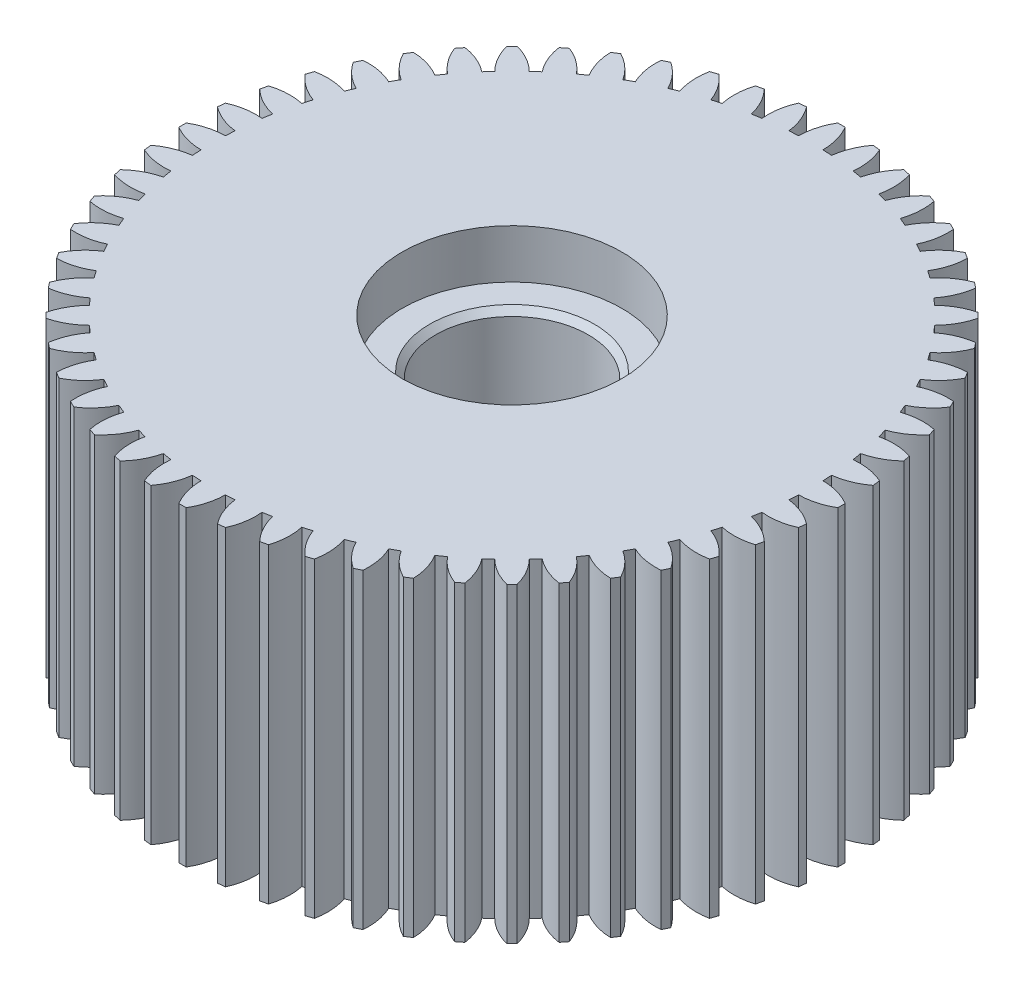
from build123d import *

# Parameters (mm, degrees)
SKETCH2_R           = 24.5
BOSS_EXTRUDE1_DEPTH = 25.5
BOSS_EXTRUDE2_DEPTH = 25.5
SKETCH4_R           = 9
CUT_EXTRUDE1_DEPTH  = 4
SKETCH5_R           = 6.25
CUT_EXTRUDE3_DEPTH  = 30
CHAMFER1_SIZE       = 0.5


with BuildPart() as part:
    # Sketch2 → Boss-Extrude1 (new body)
    with BuildSketch(Plane(origin=(0, 0, 0), x_dir=(1, 0, 0), z_dir=(0, 1, 0))):
        Circle(SKETCH2_R)
    extrude(amount=BOSS_EXTRUDE1_DEPTH)

    # Sketch3 → Boss-Extrude2 (add)
    with BuildSketch(Plane(origin=(0, 25.5, 0), x_dir=(1, 0, 0), z_dir=(0, 1, 0))):
        with BuildLine():
            Line((0.3, 26.998333282), (-0.3, 26.998333282))
            ThreePointArc((-0.3, 26.998333282), (-0.817526503, 25.785516541), (-1, 24.47958333))
            ThreePointArc((-1, 24.47958333), (0, 24.5), (1, 24.47958333))
            ThreePointArc((1, 24.47958333), (0.817526503, 25.785516541), (0.3, 26.998333282))
        make_face()
        with BuildLine():
            ThreePointArc((-1.747131513, 24.437625324), (-2.074675783, 25.714916551), (-2.724740579, 26.862162772))
            Line((-2.724740579, 26.862162772), (-3.320967905, 26.794984086))
            ThreePointArc((-3.320967905, 26.794984086), (-3.699447918, 25.531848698), (-3.734555933, 24.213696372))
            ThreePointArc((-3.734555933, 24.213696372), (-2.743129665, 24.345949142), (-1.747131513, 24.437625324))
        make_face()
        with BuildLine():
            Line((3.320967905, 26.794984086), (2.724740579, 26.862162772))
            ThreePointArc((2.724740579, 26.862162772), (2.074675783, 25.714916551), (1.747131513, 24.437625324))
            ThreePointArc((1.747131513, 24.437625324), (2.743129665, 24.345949142), (3.734555933, 24.213696372))
            ThreePointArc((3.734555933, 24.213696372), (3.699447918, 25.531848698), (3.320967905, 26.794984086))
        make_face()
        with BuildLine():
            ThreePointArc((-4.472291833, 24.088350001), (-4.940787817, 25.320936566), (-5.715215963, 26.388184979))
            Line((-5.715215963, 26.388184979), (-6.300172711, 26.254672419))
            ThreePointArc((-6.300172711, 26.254672419), (-6.534846629, 24.957103045), (-6.422147658, 23.643308133))
            ThreePointArc((-6.422147658, 23.643308133), (-5.451762882, 23.885733848), (-4.472291833, 24.088350001))
        make_face()
        with BuildLine():
            Line((6.300172711, 26.254672419), (5.715215963, 26.388184979))
            ThreePointArc((5.715215963, 26.388184979), (4.940787817, 25.320936566), (4.472291833, 24.088350001))
            ThreePointArc((4.472291833, 24.088350001), (5.451762882, 23.885733848), (6.422147658, 23.643308133))
            ThreePointArc((6.422147658, 23.643308133), (6.534846629, 24.957103045), (6.300172711, 26.254672419))
        make_face()
        with BuildLine():
            ThreePointArc((-7.141210489, 23.4361497), (-7.744766577, 24.608531113), (-8.633819192, 25.582360449))
            Line((-8.633819192, 25.582360449), (-9.20014919, 25.384193012))
            ThreePointArc((-9.20014919, 25.384193012), (-9.288065853, 24.06850734), (-9.02897715, 22.775591576))
            ThreePointArc((-9.02897715, 22.775591576), (-8.091837018, 23.125141593), (-7.141210489, 23.4361497))
        make_face()
        with BuildLine():
            Line((9.20014919, 25.384193012), (8.633819192, 25.582360449))
            ThreePointArc((8.633819192, 25.582360449), (7.744766577, 24.608531113), (7.141210489, 23.4361497))
            ThreePointArc((7.141210489, 23.4361497), (8.091837018, 23.125141593), (9.02897715, 22.775591576))
            ThreePointArc((9.02897715, 22.775591576), (9.288065853, 24.06850734), (9.20014919, 25.384193012))
        make_face()
        with BuildLine():
            ThreePointArc((-9.720324279, 22.489226218), (-10.451350404, 23.586659102), (-11.443847134, 24.454822894))
            Line((-11.443847134, 24.454822894), (-11.984428455, 24.194492651))
            ThreePointArc((-11.984428455, 24.194492651), (-11.924482259, 22.87723619), (-11.522262015, 21.62145874))
            ThreePointArc((-11.522262015, 21.62145874), (-10.630151608, 22.073737264), (-9.720324279, 22.489226218))
        make_face()
        with BuildLine():
            Line((11.984428455, 24.194492651), (11.443847134, 24.454822894))
            ThreePointArc((11.443847134, 24.454822894), (10.451350404, 23.586659102), (9.720324279, 22.489226218))
            ThreePointArc((9.720324279, 22.489226218), (10.630151608, 22.073737264), (11.522262015, 21.62145874))
            ThreePointArc((11.522262015, 21.62145874), (11.924482259, 22.87723619), (11.984428455, 24.194492651))
        make_face()
        with BuildLine():
            ThreePointArc((-12.177199352, 21.259487669), (-13.026502436, 22.268171167), (-14.109962059, 23.019751752))
            Line((-14.109962059, 23.019751752), (-14.617996578, 22.700532506))
            ThreePointArc((-14.617996578, 22.700532506), (-14.410941382, 21.398270522), (-13.87064775, 20.195423516))
            ThreePointArc((-13.87064775, 20.195423516), (-13.034785875, 20.744742881), (-12.177199352, 21.259487669))
        make_face()
        with BuildLine():
            Line((14.617996578, 22.700532506), (14.109962059, 23.019751752))
            ThreePointArc((14.109962059, 23.019751752), (13.026502436, 22.268171167), (12.177199352, 21.259487669))
            ThreePointArc((12.177199352, 21.259487669), (13.034785875, 20.744742881), (13.87064775, 20.195423516))
            ThreePointArc((13.87064775, 20.195423516), (14.410941382, 21.398270522), (14.617996578, 22.700532506))
        make_face()
        with BuildLine():
            ThreePointArc((-14.480939077, 19.762398727), (-15.437838641, 20.66964806), (-16.598636024, 21.295193875))
            Line((-16.598636024, 21.295193875), (-17.067734913, 20.921099993))
            ThreePointArc((-17.067734913, 20.921099993), (-16.716174556, 19.650209186), (-16.044602042, 18.515419123))
            ThreePointArc((-16.044602042, 18.515419123), (-15.275500146, 19.15487132), (-14.480939077, 19.762398727))
        make_face()
        with BuildLine():
            Line((17.067734913, 20.921099993), (16.598636024, 21.295193875))
            ThreePointArc((16.598636024, 21.295193875), (15.437838641, 20.66964806), (14.480939077, 19.762398727))
            ThreePointArc((14.480939077, 19.762398727), (15.275500146, 19.15487132), (16.044602042, 18.515419123))
            ThreePointArc((16.044602042, 18.515419123), (16.716174556, 19.650209186), (17.067734913, 20.921099993))
        make_face()
        with BuildLine():
            ThreePointArc((-16.602572592, 18.016786154), (-17.655035069, 18.811192136), (-18.87857251, 19.302836579))
            Line((-18.87857251, 19.302836579), (-19.302836579, 18.87857251))
            ThreePointArc((-19.302836579, 18.87857251), (-18.811192136, 17.655035069), (-18.016786154, 16.602572592))
            ThreePointArc((-18.016786154, 16.602572592), (-17.324116139, 17.324116139), (-16.602572592, 18.016786154))
        make_face()
        with BuildLine():
            Line((19.302836579, 18.87857251), (18.87857251, 19.302836579))
            ThreePointArc((18.87857251, 19.302836579), (17.655035069, 18.811192136), (16.602572592, 18.016786154))
            ThreePointArc((16.602572592, 18.016786154), (17.324116139, 17.324116139), (18.016786154, 16.602572592))
            ThreePointArc((18.016786154, 16.602572592), (18.811192136, 17.655035069), (19.302836579, 18.87857251))
        make_face()
        with BuildLine():
            ThreePointArc((-18.515419123, 16.044602042), (-19.650209186, 16.716174556), (-20.921099993, 17.067734913))
            Line((-20.921099993, 17.067734913), (-21.295193875, 16.598636024))
            ThreePointArc((-21.295193875, 16.598636024), (-20.66964806, 15.437838641), (-19.762398727, 14.480939077))
            ThreePointArc((-19.762398727, 14.480939077), (-19.15487132, 15.275500146), (-18.515419123, 16.044602042))
        make_face()
        with BuildLine():
            Line((21.295193875, 16.598636024), (20.921099993, 17.067734913))
            ThreePointArc((20.921099993, 17.067734913), (19.650209186, 16.716174556), (18.515419123, 16.044602042))
            ThreePointArc((18.515419123, 16.044602042), (19.15487132, 15.275500146), (19.762398727, 14.480939077))
            ThreePointArc((19.762398727, 14.480939077), (20.66964806, 15.437838641), (21.295193875, 16.598636024))
        make_face()
        with BuildLine():
            ThreePointArc((-20.195423516, 13.87064775), (-21.398270522, 14.410941382), (-22.700532506, 14.617996578))
            Line((-22.700532506, 14.617996578), (-23.019751752, 14.109962059))
            ThreePointArc((-23.019751752, 14.109962059), (-22.268171167, 13.026502436), (-21.259487669, 12.177199352))
            ThreePointArc((-21.259487669, 12.177199352), (-20.744742881, 13.034785875), (-20.195423516, 13.87064775))
        make_face()
        with BuildLine():
            Line((23.019751752, 14.109962059), (22.700532506, 14.617996578))
            ThreePointArc((22.700532506, 14.617996578), (21.398270522, 14.410941382), (20.195423516, 13.87064775))
            ThreePointArc((20.195423516, 13.87064775), (20.744742881, 13.034785875), (21.259487669, 12.177199352))
            ThreePointArc((21.259487669, 12.177199352), (22.268171167, 13.026502436), (23.019751752, 14.109962059))
        make_face()
        with BuildLine():
            ThreePointArc((-21.62145874, 11.522262015), (-22.87723619, 11.924482259), (-24.19449265, 11.984428455))
            Line((-24.19449265, 11.984428455), (-24.454822894, 11.443847134))
            ThreePointArc((-24.454822894, 11.443847134), (-23.586659102, 10.451350404), (-22.489226218, 9.720324279))
            ThreePointArc((-22.489226218, 9.720324279), (-22.073737264, 10.630151608), (-21.62145874, 11.522262015))
        make_face()
        with BuildLine():
            Line((24.454822894, 11.443847134), (24.194492651, 11.984428455))
            ThreePointArc((24.194492651, 11.984428455), (22.87723619, 11.924482259), (21.62145874, 11.522262015))
            ThreePointArc((21.62145874, 11.522262015), (22.073737264, 10.630151608), (22.489226218, 9.720324279))
            ThreePointArc((22.489226218, 9.720324279), (23.586659102, 10.451350404), (24.454822894, 11.443847134))
        make_face()
        with BuildLine():
            ThreePointArc((-22.775591576, 9.02897715), (-24.06850734, 9.288065853), (-25.384193012, 9.20014919))
            Line((-25.384193012, 9.20014919), (-25.582360449, 8.633819192))
            ThreePointArc((-25.582360449, 8.633819192), (-24.608531113, 7.744766577), (-23.4361497, 7.141210489))
            ThreePointArc((-23.4361497, 7.141210489), (-23.125141593, 8.091837018), (-22.775591576, 9.02897715))
        make_face()
        with BuildLine():
            Line((25.582360449, 8.633819192), (25.384193012, 9.20014919))
            ThreePointArc((25.384193012, 9.20014919), (24.06850734, 9.288065853), (22.775591576, 9.02897715))
            ThreePointArc((22.775591576, 9.02897715), (23.125141593, 8.091837018), (23.4361497, 7.141210489))
            ThreePointArc((23.4361497, 7.141210489), (24.608531113, 7.744766577), (25.582360449, 8.633819192))
        make_face()
        with BuildLine():
            ThreePointArc((-23.643308133, 6.422147658), (-24.957103045, 6.534846629), (-26.254672419, 6.300172711))
            Line((-26.254672419, 6.300172711), (-26.388184979, 5.715215963))
            ThreePointArc((-26.388184979, 5.715215963), (-25.320936566, 4.940787817), (-24.088350001, 4.472291833))
            ThreePointArc((-24.088350001, 4.472291833), (-23.885733848, 5.451762882), (-23.643308133, 6.422147658))
        make_face()
        with BuildLine():
            Line((26.388184979, 5.715215963), (26.254672419, 6.300172711))
            ThreePointArc((26.254672419, 6.300172711), (24.957103045, 6.534846629), (23.643308133, 6.422147658))
            ThreePointArc((23.643308133, 6.422147658), (23.885733848, 5.451762882), (24.088350001, 4.472291833))
            ThreePointArc((24.088350001, 4.472291833), (25.320936566, 4.940787817), (26.388184979, 5.715215963))
        make_face()
        with BuildLine():
            ThreePointArc((-24.213696372, 3.734555933), (-25.531848698, 3.699447918), (-26.794984086, 3.320967905))
            Line((-26.794984086, 3.320967905), (-26.862162772, 2.724740579))
            ThreePointArc((-26.862162772, 2.724740579), (-25.714916551, 2.074675783), (-24.437625324, 1.747131513))
            ThreePointArc((-24.437625324, 1.747131513), (-24.345949142, 2.743129665), (-24.213696372, 3.734555933))
        make_face()
        with BuildLine():
            Line((26.862162772, 2.724740579), (26.794984086, 3.320967905))
            ThreePointArc((26.794984086, 3.320967905), (25.531848698, 3.699447918), (24.213696372, 3.734555933))
            ThreePointArc((24.213696372, 3.734555933), (24.345949142, 2.743129665), (24.437625324, 1.747131513))
            ThreePointArc((24.437625324, 1.747131513), (25.714916551, 2.074675783), (26.862162772, 2.724740579))
        make_face()
        with BuildLine():
            ThreePointArc((-24.47958333, 1), (-25.785516541, 0.817526503), (-26.998333282, 0.3))
            Line((-26.998333282, 0.3), (-26.998333282, -0.3))
            ThreePointArc((-26.998333282, -0.3), (-25.785516541, -0.817526503), (-24.47958333, -1))
            ThreePointArc((-24.47958333, -1), (-24.5, 0), (-24.47958333, 1))
        make_face()
        with BuildLine():
            Line((26.998333282, -0.3), (26.998333282, 0.3))
            ThreePointArc((26.998333282, 0.3), (25.785516541, 0.817526503), (24.47958333, 1))
            ThreePointArc((24.47958333, 1), (24.5, 0), (24.47958333, -1))
            ThreePointArc((24.47958333, -1), (25.785516541, -0.817526503), (26.998333282, -0.3))
        make_face()
        with BuildLine():
            ThreePointArc((-24.437625324, -1.747131513), (-25.714916551, -2.074675783), (-26.862162772, -2.724740579))
            Line((-26.862162772, -2.724740579), (-26.794984086, -3.320967905))
            ThreePointArc((-26.794984086, -3.320967905), (-25.531848698, -3.699447918), (-24.213696372, -3.734555933))
            ThreePointArc((-24.213696372, -3.734555933), (-24.345949142, -2.743129665), (-24.437625324, -1.747131513))
        make_face()
        with BuildLine():
            Line((26.794984086, -3.320967905), (26.862162772, -2.724740579))
            ThreePointArc((26.862162772, -2.724740579), (25.714916551, -2.074675783), (24.437625324, -1.747131513))
            ThreePointArc((24.437625324, -1.747131513), (24.345949142, -2.743129665), (24.213696372, -3.734555933))
            ThreePointArc((24.213696372, -3.734555933), (25.531848698, -3.699447918), (26.794984086, -3.320967905))
        make_face()
        with BuildLine():
            ThreePointArc((-24.088350001, -4.472291833), (-25.320936566, -4.940787817), (-26.388184979, -5.715215963))
            Line((-26.388184979, -5.715215963), (-26.254672419, -6.300172711))
            ThreePointArc((-26.254672419, -6.300172711), (-24.957103045, -6.534846629), (-23.643308133, -6.422147658))
            ThreePointArc((-23.643308133, -6.422147658), (-23.885733848, -5.451762882), (-24.088350001, -4.472291833))
        make_face()
        with BuildLine():
            Line((26.254672419, -6.300172711), (26.388184979, -5.715215963))
            ThreePointArc((26.388184979, -5.715215963), (25.320936566, -4.940787817), (24.088350001, -4.472291833))
            ThreePointArc((24.088350001, -4.472291833), (23.885733848, -5.451762882), (23.643308133, -6.422147658))
            ThreePointArc((23.643308133, -6.422147658), (24.957103045, -6.534846629), (26.254672419, -6.300172711))
        make_face()
        with BuildLine():
            ThreePointArc((-23.4361497, -7.141210489), (-24.608531113, -7.744766577), (-25.582360449, -8.633819192))
            Line((-25.582360449, -8.633819192), (-25.384193012, -9.20014919))
            ThreePointArc((-25.384193012, -9.20014919), (-24.06850734, -9.288065853), (-22.775591576, -9.02897715))
            ThreePointArc((-22.775591576, -9.02897715), (-23.125141593, -8.091837018), (-23.4361497, -7.141210489))
        make_face()
        with BuildLine():
            Line((25.384193012, -9.20014919), (25.582360449, -8.633819192))
            ThreePointArc((25.582360449, -8.633819192), (24.608531113, -7.744766577), (23.4361497, -7.141210489))
            ThreePointArc((23.4361497, -7.141210489), (23.125141593, -8.091837018), (22.775591576, -9.02897715))
            ThreePointArc((22.775591576, -9.02897715), (24.06850734, -9.288065853), (25.384193012, -9.20014919))
        make_face()
        with BuildLine():
            ThreePointArc((-22.489226218, -9.720324279), (-23.586659102, -10.451350404), (-24.454822894, -11.443847134))
            Line((-24.454822894, -11.443847134), (-24.19449265, -11.984428455))
            ThreePointArc((-24.19449265, -11.984428455), (-22.87723619, -11.924482259), (-21.62145874, -11.522262015))
            ThreePointArc((-21.62145874, -11.522262015), (-22.073737264, -10.630151608), (-22.489226218, -9.720324279))
        make_face()
        with BuildLine():
            Line((24.194492651, -11.984428455), (24.454822894, -11.443847134))
            ThreePointArc((24.454822894, -11.443847134), (23.586659102, -10.451350404), (22.489226218, -9.720324279))
            ThreePointArc((22.489226218, -9.720324279), (22.073737264, -10.630151608), (21.62145874, -11.522262015))
            ThreePointArc((21.62145874, -11.522262015), (22.87723619, -11.924482259), (24.194492651, -11.984428455))
        make_face()
        with BuildLine():
            ThreePointArc((-21.259487669, -12.177199352), (-22.268171167, -13.026502436), (-23.019751752, -14.109962059))
            Line((-23.019751752, -14.109962059), (-22.700532506, -14.617996578))
            ThreePointArc((-22.700532506, -14.617996578), (-21.398270522, -14.410941382), (-20.195423516, -13.87064775))
            ThreePointArc((-20.195423516, -13.87064775), (-20.744742881, -13.034785875), (-21.259487669, -12.177199352))
        make_face()
        with BuildLine():
            Line((22.700532506, -14.617996578), (23.019751752, -14.109962059))
            ThreePointArc((23.019751752, -14.109962059), (22.268171167, -13.026502436), (21.259487669, -12.177199352))
            ThreePointArc((21.259487669, -12.177199352), (20.744742881, -13.034785875), (20.195423516, -13.87064775))
            ThreePointArc((20.195423516, -13.87064775), (21.398270522, -14.410941382), (22.700532506, -14.617996578))
        make_face()
        with BuildLine():
            ThreePointArc((-19.762398727, -14.480939077), (-20.66964806, -15.437838641), (-21.295193874, -16.598636024))
            Line((-21.295193874, -16.598636024), (-20.921099993, -17.067734913))
            ThreePointArc((-20.921099993, -17.067734913), (-19.650209186, -16.716174556), (-18.515419123, -16.044602042))
            ThreePointArc((-18.515419123, -16.044602042), (-19.15487132, -15.275500146), (-19.762398727, -14.480939077))
        make_face()
        with BuildLine():
            Line((20.921099993, -17.067734913), (21.295193875, -16.598636024))
            ThreePointArc((21.295193875, -16.598636024), (20.66964806, -15.437838641), (19.762398727, -14.480939077))
            ThreePointArc((19.762398727, -14.480939077), (19.15487132, -15.275500146), (18.515419123, -16.044602042))
            ThreePointArc((18.515419123, -16.044602042), (19.650209186, -16.716174556), (20.921099993, -17.067734913))
        make_face()
        with BuildLine():
            ThreePointArc((-18.016786154, -16.602572592), (-18.811192136, -17.655035069), (-19.302836579, -18.87857251))
            Line((-19.302836579, -18.87857251), (-18.87857251, -19.302836579))
            ThreePointArc((-18.87857251, -19.302836579), (-17.655035069, -18.811192136), (-16.602572592, -18.016786154))
            ThreePointArc((-16.602572592, -18.016786154), (-17.324116139, -17.324116139), (-18.016786154, -16.602572592))
        make_face()
        with BuildLine():
            Line((18.87857251, -19.302836579), (19.302836579, -18.87857251))
            ThreePointArc((19.302836579, -18.87857251), (18.811192136, -17.655035069), (18.016786154, -16.602572592))
            ThreePointArc((18.016786154, -16.602572592), (17.324116139, -17.324116139), (16.602572592, -18.016786154))
            ThreePointArc((16.602572592, -18.016786154), (17.655035069, -18.811192136), (18.87857251, -19.302836579))
        make_face()
        with BuildLine():
            ThreePointArc((-16.044602042, -18.515419123), (-16.716174556, -19.650209186), (-17.067734913, -20.921099993))
            Line((-17.067734913, -20.921099993), (-16.598636024, -21.295193875))
            ThreePointArc((-16.598636024, -21.295193875), (-15.437838641, -20.66964806), (-14.480939077, -19.762398727))
            ThreePointArc((-14.480939077, -19.762398727), (-15.275500146, -19.15487132), (-16.044602042, -18.515419123))
        make_face()
        with BuildLine():
            Line((16.598636024, -21.295193875), (17.067734913, -20.921099993))
            ThreePointArc((17.067734913, -20.921099993), (16.716174556, -19.650209186), (16.044602042, -18.515419123))
            ThreePointArc((16.044602042, -18.515419123), (15.275500146, -19.15487132), (14.480939077, -19.762398727))
            ThreePointArc((14.480939077, -19.762398727), (15.437838641, -20.66964806), (16.598636024, -21.295193875))
        make_face()
        with BuildLine():
            ThreePointArc((-13.87064775, -20.195423516), (-14.410941382, -21.398270522), (-14.617996578, -22.700532506))
            Line((-14.617996578, -22.700532506), (-14.109962059, -23.019751752))
            ThreePointArc((-14.109962059, -23.019751752), (-13.026502436, -22.268171167), (-12.177199352, -21.259487669))
            ThreePointArc((-12.177199352, -21.259487669), (-13.034785875, -20.744742881), (-13.87064775, -20.195423516))
        make_face()
        with BuildLine():
            Line((14.109962059, -23.019751752), (14.617996578, -22.700532506))
            ThreePointArc((14.617996578, -22.700532506), (14.410941382, -21.398270522), (13.87064775, -20.195423516))
            ThreePointArc((13.87064775, -20.195423516), (13.034785875, -20.744742881), (12.177199352, -21.259487669))
            ThreePointArc((12.177199352, -21.259487669), (13.026502436, -22.268171167), (14.109962059, -23.019751752))
        make_face()
        with BuildLine():
            ThreePointArc((-11.522262015, -21.62145874), (-11.924482259, -22.87723619), (-11.984428455, -24.194492651))
            Line((-11.984428455, -24.194492651), (-11.443847134, -24.454822894))
            ThreePointArc((-11.443847134, -24.454822894), (-10.451350404, -23.586659102), (-9.720324279, -22.489226218))
            ThreePointArc((-9.720324279, -22.489226218), (-10.630151608, -22.073737264), (-11.522262015, -21.62145874))
        make_face()
        with BuildLine():
            Line((11.443847134, -24.454822894), (11.984428455, -24.19449265))
            ThreePointArc((11.984428455, -24.19449265), (11.924482259, -22.87723619), (11.522262015, -21.62145874))
            ThreePointArc((11.522262015, -21.62145874), (10.630151608, -22.073737264), (9.720324279, -22.489226218))
            ThreePointArc((9.720324279, -22.489226218), (10.451350404, -23.586659102), (11.443847134, -24.454822894))
        make_face()
        with BuildLine():
            ThreePointArc((-9.02897715, -22.775591576), (-9.288065853, -24.06850734), (-9.20014919, -25.384193012))
            Line((-9.20014919, -25.384193012), (-8.633819192, -25.582360449))
            ThreePointArc((-8.633819192, -25.582360449), (-7.744766577, -24.608531113), (-7.141210489, -23.4361497))
            ThreePointArc((-7.141210489, -23.4361497), (-8.091837018, -23.125141593), (-9.02897715, -22.775591576))
        make_face()
        with BuildLine():
            Line((8.633819192, -25.582360449), (9.20014919, -25.384193012))
            ThreePointArc((9.20014919, -25.384193012), (9.288065853, -24.06850734), (9.02897715, -22.775591576))
            ThreePointArc((9.02897715, -22.775591576), (8.091837018, -23.125141593), (7.141210489, -23.4361497))
            ThreePointArc((7.141210489, -23.4361497), (7.744766577, -24.608531113), (8.633819192, -25.582360449))
        make_face()
        with BuildLine():
            ThreePointArc((-6.422147658, -23.643308133), (-6.534846629, -24.957103045), (-6.300172711, -26.254672419))
            Line((-6.300172711, -26.254672419), (-5.715215963, -26.388184979))
            ThreePointArc((-5.715215963, -26.388184979), (-4.940787817, -25.320936566), (-4.472291833, -24.088350001))
            ThreePointArc((-4.472291833, -24.088350001), (-5.451762882, -23.885733848), (-6.422147658, -23.643308133))
        make_face()
        with BuildLine():
            Line((5.715215964, -26.388184979), (6.300172711, -26.254672419))
            ThreePointArc((6.300172711, -26.254672419), (6.534846629, -24.957103045), (6.422147658, -23.643308133))
            ThreePointArc((6.422147658, -23.643308133), (5.451762882, -23.885733848), (4.472291833, -24.088350001))
            ThreePointArc((4.472291833, -24.088350001), (4.940787817, -25.320936566), (5.715215964, -26.388184979))
        make_face()
        with BuildLine():
            ThreePointArc((-3.734555933, -24.213696372), (-3.699447918, -25.531848698), (-3.320967905, -26.794984086))
            Line((-3.320967905, -26.794984086), (-2.724740579, -26.862162772))
            ThreePointArc((-2.724740579, -26.862162772), (-2.074675783, -25.714916551), (-1.747131513, -24.437625324))
            ThreePointArc((-1.747131513, -24.437625324), (-2.743129665, -24.345949142), (-3.734555933, -24.213696372))
        make_face()
        with BuildLine():
            Line((2.724740579, -26.862162772), (3.320967905, -26.794984086))
            ThreePointArc((3.320967905, -26.794984086), (3.699447918, -25.531848698), (3.734555933, -24.213696372))
            ThreePointArc((3.734555933, -24.213696372), (2.743129665, -24.345949142), (1.747131513, -24.437625324))
            ThreePointArc((1.747131513, -24.437625324), (2.074675783, -25.714916551), (2.724740579, -26.862162772))
        make_face()
        with BuildLine():
            ThreePointArc((-1, -24.47958333), (-0.817526503, -25.785516541), (-0.3, -26.998333282))
            Line((-0.3, -26.998333282), (0.3, -26.998333282))
            ThreePointArc((0.3, -26.998333282), (0.817526503, -25.785516541), (1, -24.47958333))
            ThreePointArc((1, -24.47958333), (0, -24.5), (-1, -24.47958333))
        make_face()
    extrude(amount=-BOSS_EXTRUDE2_DEPTH)

    # Sketch4 → Cut-Extrude1 (cut)
    with BuildSketch(Plane(origin=(0, 25.5, 0), x_dir=(1, 0, 0), z_dir=(0, 1, 0))):
        Circle(SKETCH4_R)
    extrude(amount=-CUT_EXTRUDE1_DEPTH, mode=Mode.SUBTRACT)

    # Sketch5 → Cut-Extrude3 (cut)
    with BuildSketch(Plane(origin=(0, 21.5, 0), x_dir=(1, 0, 0), z_dir=(0, 1, 0))):
        Circle(SKETCH5_R)
    extrude(amount=-CUT_EXTRUDE3_DEPTH, mode=Mode.SUBTRACT)

    # Chamfer1
    chamfer1_edges = [part.edges().sort_by_distance(p)[0] for p in [
        (-6.25, 21.5, 0),
    ]]
    chamfer(chamfer1_edges, length=CHAMFER1_SIZE)


solid = part.part
